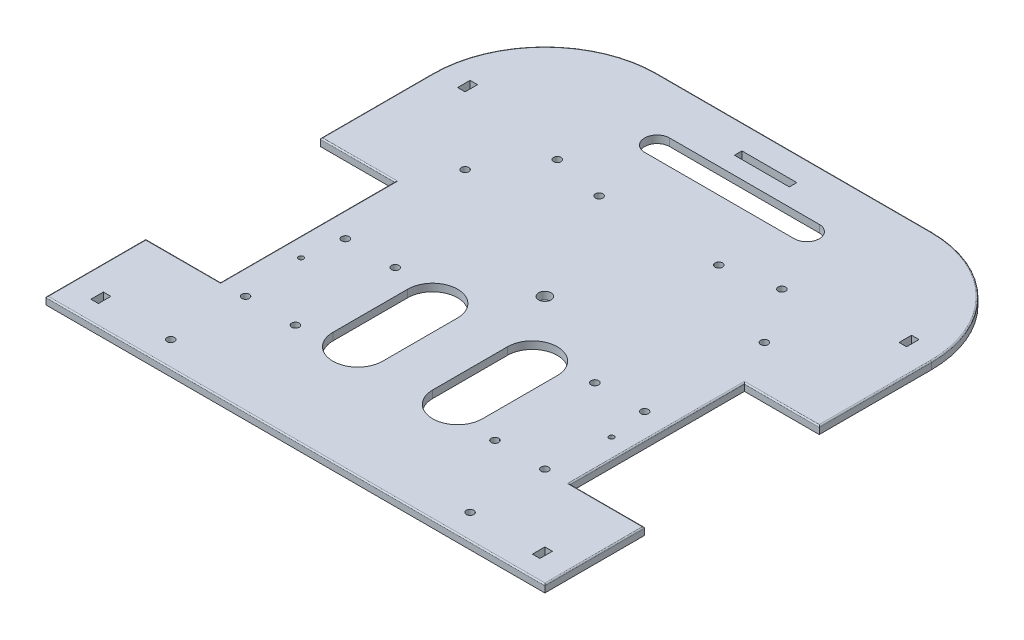
from build123d import *

# Parameters (mm, degrees)
SKETCH1_W               = 200
SKETCH1_H               = 200
BOSS_EXTRUDE1_DEPTH     = 3
CUT_EXTRUDE1_START      = -142.453172464
SKETCH2_W               = 30
SKETCH2_H               = 70
CUT_EXTRUDE1_DEPTH      = 152.453172464
SKETCH4_W               = 3
SKETCH4_H               = 5
CUT_EXTRUDE2_DEPTH      = 142.453172464
SKETCH5_W               = 3
SKETCH5_H               = 5
CUT_EXTRUDE3_DEPTH      = 142.453172464
CUT_EXTRUDE4_DEPTH      = 142.453172464
FILLET1_R               = 45
SKETCH9_R               = 1.5
SKETCH9_W               = 22
SKETCH9_H               = 3
CUT_EXTRUDE7_DEPTH      = 142.453172464
SKETCH11_R              = 1.5
CUT_EXTRUDE8_DEPTH      = 142.453172464
SKETCH10_R              = 1.5
CUT_EXTRUDE9_DEPTH      = 142.453172464
LPATTERN1_COUNT         = 2
LPATTERN1_PITCH         = 40
LPATTERN1_COUNT_DIR2    = 2
LPATTERN1_PITCH_DIR2    = 20
SKETCH13_R              = 1.5
CUT_EXTRUDE10_DEPTH     = 142.453172464
MIRROR1_COPY_1_SKETCH_R = 1.5
MIRROR1_COPY_1_DEPTH    = 142.453172464
MIRROR1_COPY_2_SKETCH_R = 1.5
MIRROR1_COPY_2_DEPTH    = 142.453172464
MIRROR1_COPY_3_SKETCH_R = 1.5
MIRROR1_COPY_3_DEPTH    = 142.453172464
FILLET2_R               = 0.5
SKETCH23_W              = 20
SKETCH23_H              = 5.000586006
BOSS_EXTRUDE7_DEPTH     = 10
SKETCH26_R              = 1.5
CUT_EXTRUDE11_DEPTH     = 10
SKETCH27_R              = 2.5
CUT_EXTRUDE12_DEPTH     = 10
SKETCH28_R              = 1
CUT_EXTRUDE13_DEPTH     = 10


with BuildPart() as part:
    # Sketch1 → Boss-Extrude1 (new body)
    with BuildSketch(Plane(origin=(0, 0, 0), x_dir=(1, 0, 0), z_dir=(0, 1, 0))):
        Rectangle(SKETCH1_W, SKETCH1_H)
    extrude(amount=BOSS_EXTRUDE1_DEPTH)

    # Sketch2 → Cut-Extrude1 (cut)
    with BuildSketch(Plane(origin=(0, 3, 0), x_dir=(1, 0, 0), z_dir=(0, 1, 0)).offset(CUT_EXTRUDE1_START)):
        with Locations((-85, -25)):
            Rectangle(SKETCH2_W, SKETCH2_H)
    cut_extrude1 = extrude(amount=CUT_EXTRUDE1_DEPTH, mode=Mode.SUBTRACT)

    # Sketch4 → Cut-Extrude2 (cut, through all)
    with BuildSketch(Plane(origin=(0, 3, 0), x_dir=(1, 0, 0), z_dir=(0, 1, 0))):
        with Locations((-88.5, -89.5)):
            Rectangle(SKETCH4_W, SKETCH4_H)
    cut_extrude2 = extrude(amount=-CUT_EXTRUDE2_DEPTH, mode=Mode.SUBTRACT)

    # Sketch5 → Cut-Extrude3 (cut, through all)
    with BuildSketch(Plane(origin=(0, 3, 0), x_dir=(1, 0, 0), z_dir=(0, 1, 0))):
        with Locations((-88.5, 57.5)):
            Rectangle(SKETCH5_W, SKETCH5_H)
    cut_extrude3 = extrude(amount=-CUT_EXTRUDE3_DEPTH, mode=Mode.SUBTRACT)

    # Sketch7 → Cut-Extrude4 (cut, through all)
    with BuildSketch(Plane(origin=(0, 3, 0), x_dir=(1, 0, 0), z_dir=(0, 1, 0))):
        with BuildLine():
            Line((-30, -55), (-30, -25))
            ThreePointArc((-30, -25), (-20, -15), (-10, -25))
            Line((-10, -25), (-10, -55))
            ThreePointArc((-10, -55), (-20, -65), (-30, -55))
        make_face()
    cut_extrude4 = extrude(amount=-CUT_EXTRUDE4_DEPTH, mode=Mode.SUBTRACT)

    # Fillet1
    fillet1_edges = [part.edges().sort_by_distance(p)[0] for p in [
        (100, 1.5, -100),
        (-100, 1.5, -100),
    ]]
    fillet(fillet1_edges, radius=FILLET1_R)

    # Sketch9 → Cut-Extrude7 (cut, through all)
    with BuildSketch(Plane(origin=(0, 3, 0), x_dir=(1, 0, 0), z_dir=(0, 1, 0))):
        with Locations((-60, -90)):
            Circle(SKETCH9_R)
        with BuildLine():
            Line((-30, 80), (30, 80))
            ThreePointArc((30, 80), (35, 75), (30, 70))
            Line((30, 70), (-30, 70))
            ThreePointArc((-30, 70), (-35, 75), (-30, 80))
        make_face()
        with Locations((0, 88.5)):
            Rectangle(SKETCH9_W, SKETCH9_H)
    cut_extrude7 = extrude(amount=-CUT_EXTRUDE7_DEPTH, mode=Mode.SUBTRACT)

    # Sketch11 → Cut-Extrude8 (cut, through all)
    with BuildSketch(Plane(origin=(0, 3, 0), x_dir=(1, 0, 0), z_dir=(0, 1, 0))):
        with Locations((-45, 50)):
            Circle(SKETCH11_R)
    cut_extrude8 = extrude(amount=-CUT_EXTRUDE8_DEPTH, mode=Mode.SUBTRACT)

    # Sketch10 → Cut-Extrude9 (cut, through all)
    with BuildSketch(Plane(origin=(0, 3, 0), x_dir=(1, 0, 0), z_dir=(0, 1, 0))):
        with Locations((-60, -60)):
            Circle(SKETCH10_R)
    cut_extrude9 = extrude(amount=-CUT_EXTRUDE9_DEPTH, mode=Mode.SUBTRACT)

    # LPattern1: Cut-Extrude9 2 × 2
    with Locations(*[(j * LPATTERN1_PITCH_DIR2, 0, -i * LPATTERN1_PITCH) for i in range(LPATTERN1_COUNT) for j in range(LPATTERN1_COUNT_DIR2) if (i, j) != (0, 0)]):
        add(cut_extrude9, mode=Mode.SUBTRACT)

    # Sketch13 → Cut-Extrude10 (cut, through all)
    with BuildSketch(Plane(origin=(0, 3, 0), x_dir=(1, 0, 0), z_dir=(0, 1, 0))):
        with Locations((-60, 28)):
            Circle(SKETCH13_R)
    cut_extrude10 = extrude(amount=-CUT_EXTRUDE10_DEPTH, mode=Mode.SUBTRACT)

    # Mirror1: Cut-Extrude1, Cut-Extrude2, Cut-Extrude3, Cut-Extrude4, Cut-Extrude7, Cut-Extrude8, Cut-Extrude9, Cut-Extrude10 across plane
    add(cut_extrude1.mirror(Plane(origin=(0, 0, 0), x_dir=(0, 0, 1), z_dir=(1, 0, 0))), mode=Mode.SUBTRACT)
    add(cut_extrude2.mirror(Plane(origin=(0, 0, 0), x_dir=(0, 0, 1), z_dir=(1, 0, 0))), mode=Mode.SUBTRACT)
    add(cut_extrude3.mirror(Plane(origin=(0, 0, 0), x_dir=(0, 0, 1), z_dir=(1, 0, 0))), mode=Mode.SUBTRACT)
    add(cut_extrude4.mirror(Plane(origin=(0, 0, 0), x_dir=(0, 0, 1), z_dir=(1, 0, 0))), mode=Mode.SUBTRACT)
    add(cut_extrude7.mirror(Plane(origin=(0, 0, 0), x_dir=(0, 0, 1), z_dir=(1, 0, 0))), mode=Mode.SUBTRACT)
    add(cut_extrude8.mirror(Plane(origin=(0, 0, 0), x_dir=(0, 0, 1), z_dir=(1, 0, 0))), mode=Mode.SUBTRACT)
    add(cut_extrude9.mirror(Plane(origin=(0, 0, 0), x_dir=(0, 0, 1), z_dir=(1, 0, 0))), mode=Mode.SUBTRACT)
    add(cut_extrude10.mirror(Plane(origin=(0, 0, 0), x_dir=(0, 0, 1), z_dir=(1, 0, 0))), mode=Mode.SUBTRACT)

    # Mirror1 copy 1 sketch → Mirror1 copy 1 (cut, through all)
    with BuildSketch(Plane(origin=(-20, 3, 0), x_dir=(-1, 0, 0), z_dir=(0, 1, 0))):
        with Locations((-60, 60)):
            Circle(MIRROR1_COPY_1_SKETCH_R)
    extrude(amount=-MIRROR1_COPY_1_DEPTH, mode=Mode.SUBTRACT)

    # Mirror1 copy 2 sketch → Mirror1 copy 2 (cut, through all)
    with BuildSketch(Plane(origin=(0, 3, -40), x_dir=(-1, 0, 0), z_dir=(0, 1, 0))):
        with Locations((-60, 60)):
            Circle(MIRROR1_COPY_2_SKETCH_R)
    extrude(amount=-MIRROR1_COPY_2_DEPTH, mode=Mode.SUBTRACT)

    # Mirror1 copy 3 sketch → Mirror1 copy 3 (cut, through all)
    with BuildSketch(Plane(origin=(-20, 3, -40), x_dir=(-1, 0, 0), z_dir=(0, 1, 0))):
        with Locations((-60, 60)):
            Circle(MIRROR1_COPY_3_SKETCH_R)
    extrude(amount=-MIRROR1_COPY_3_DEPTH, mode=Mode.SUBTRACT)

    # Fillet2
    fillet2_edges = [part.edges().sort_by_distance(p)[0] for p in [
        (-86.819805153, 3, -86.819805153),
        (100, 3, -32.5),
        (86.819805153, 3, -86.819805153),
        (0, 3, -100),
        (85, 3, -10),
        (100, 3, 80),
        (85, 3, 60),
        (70, 3, 25),
        (0, 3, 100),
        (-100, 3, 80),
        (-85, 3, 60),
        (-100, 3, -32.5),
        (-85, 3, -10),
        (-70, 3, 25),
    ]]
    fillet(fillet2_edges, radius=FILLET2_R)

    # Sketch23 → Boss-Extrude7 (add)
    with BuildSketch(Plane.XZ):
        with Locations((0, -92.999706997)):
            Rectangle(SKETCH23_W, SKETCH23_H)
    extrude(amount=BOSS_EXTRUDE7_DEPTH)

    # Sketch26 → Cut-Extrude11 (cut)
    with BuildSketch(Plane(origin=(0, 3, 0), x_dir=(1, 0, 0), z_dir=(0, 1, 0))):
        with Locations((24, 45.74141283)):
            Circle(SKETCH26_R)
        with Locations((-24, 45.74141283)):
            Circle(SKETCH26_R)
    extrude(amount=-CUT_EXTRUDE11_DEPTH, mode=Mode.SUBTRACT)

    # Sketch27 → Cut-Extrude12 (cut)
    with BuildSketch(Plane(origin=(0, 3, 0), x_dir=(1, 0, 0), z_dir=(0, 1, 0))):
        Circle(SKETCH27_R)
    extrude(amount=-CUT_EXTRUDE12_DEPTH, mode=Mode.SUBTRACT)

    # Sketch28 → Cut-Extrude13 (cut)
    with BuildSketch(Plane(origin=(0, 3, 0), x_dir=(1, 0, 0), z_dir=(0, 1, 0))):
        with Locations((-62.25, -35.5)):
            Circle(SKETCH28_R)
        with Locations((62.25, -35.5)):
            Circle(SKETCH28_R)
    extrude(amount=-CUT_EXTRUDE13_DEPTH, mode=Mode.SUBTRACT)


solid = part.part
